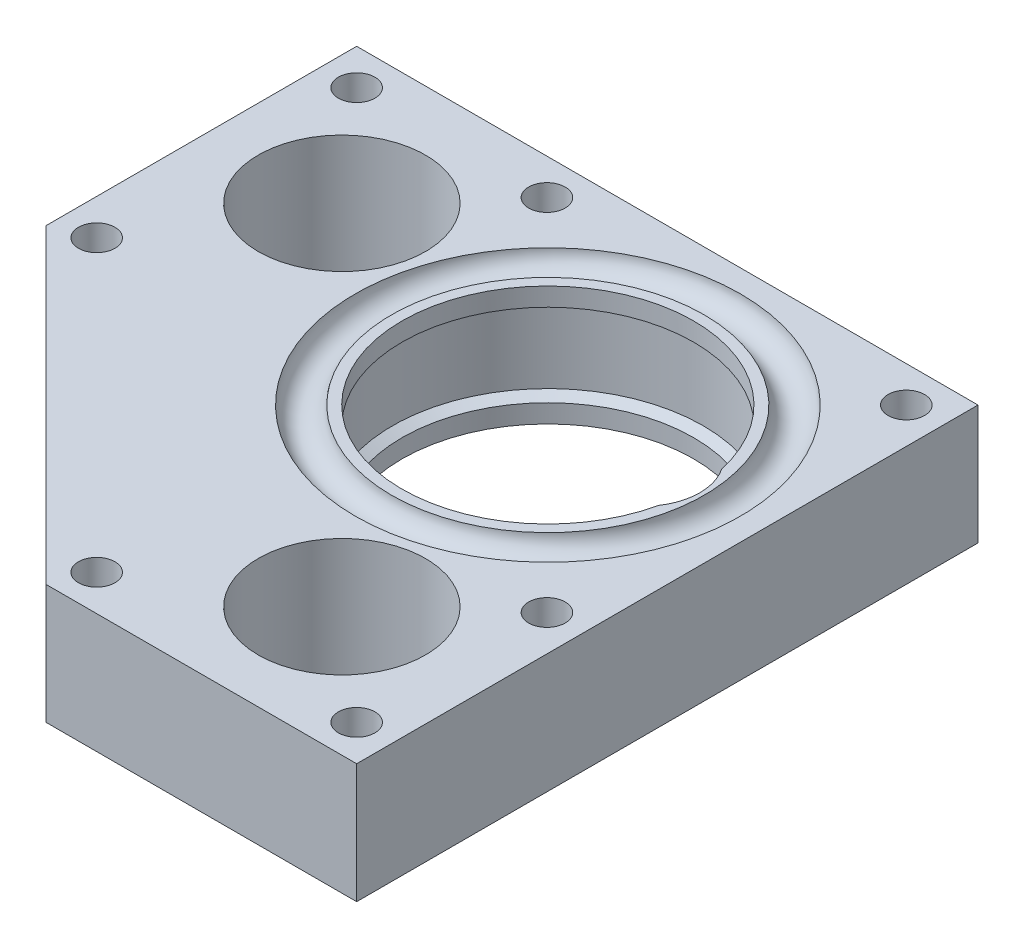
from build123d import *

# Parameters (mm, degrees)
SKETCH3_R               = 7.493
CUT_EXTRUDE2_DEPTH      = 8.9375
CUT_EXTRUDE2_DEPTH_BACK = 8.9375
SKETCH4_R               = 11.1125
SKETCH4_R_2             = 26.924
BOSS_EXTRUDE1_DEPTH     = 15.875
BOSS_EXTRUDE2_START     = 22.225
SKETCH7_R               = 6.35
BOSS_EXTRUDE2_DEPTH     = 4.7625
SKETCH5_R               = 2.4257
CUT_EXTRUDE3_DEPTH      = 27.9875
CUT_EXTRUDE3_DEPTH_BACK = 16.8750001


with BuildPart() as part:
    # Sketch1 → Revolve1 (revolve)
    with BuildSketch(Plane(origin=(0, 0, 0), x_dir=(0, 0, -1), z_dir=(1, 0, 0))):
        with BuildLine():
            Line((-20.6375, 0), (-26.9875, 0))
            Line((-26.9875, 0), (-26.9875, 7.9375))
            Line((-26.9875, 7.9375), (-25.587155577, 7.9375))
            ThreePointArc((-25.587155577, 7.9375), (-23.1775, 5.6515), (-20.767844423, 7.9375))
            Line((-20.767844423, 7.9375), (-19.3675, 7.9375))
            Line((-19.3675, 7.9375), (-19.3675, 5.495734842))
            Line((-19.3675, 5.495734842), (-20.6375, 4.7625))
            Line((-20.6375, 4.7625), (-20.6375, 0))
        make_face()
    revolve(axis=Axis((0, 0, 0), (0, 1, 0)))

    # Mirror1: part across plane


with BuildPart() as part_1:
    add(part.part)
    add(part.part.mirror(Plane(origin=(0, 0, 20.6375), x_dir=(0, 0, 1), z_dir=(0, 1, 0))))

    # Sketch3 → Cut-Extrude2 (cut, two sides)
    with BuildSketch(Plane(origin=(0, 0, 0), x_dir=(1, 0, 0), z_dir=(0, 1, 0))) as cut_extrude2_sk:
        with Locations((12.7, 0)):
            Circle(SKETCH3_R)
    extrude(amount=CUT_EXTRUDE2_DEPTH, mode=Mode.SUBTRACT)
    extrude(cut_extrude2_sk.sketch, amount=-CUT_EXTRUDE2_DEPTH_BACK, mode=Mode.SUBTRACT)

    # Sketch4 → Boss-Extrude1 (add, through all)
    with BuildSketch(Plane(origin=(0, 7.9375, 0), x_dir=(1, 0, 0), z_dir=(0, 1, 0))):
        Polygon((28.575, 28.575), (-53.975, 28.575), (-53.975, -12.7), (-12.7, -53.975), (28.575, -53.975), align=None)
        with Locations((-36.890166373, 9.525)):
            Circle(SKETCH4_R, mode=Mode.SUBTRACT)
        with Locations((9.525, -36.890166373)):
            Circle(SKETCH4_R, mode=Mode.SUBTRACT)
        Circle(SKETCH4_R_2, mode=Mode.SUBTRACT)
    extrude(amount=-BOSS_EXTRUDE1_DEPTH)


with BuildPart() as body_2:
    # Sketch7 → Boss-Extrude2 (new body)
    with BuildSketch(Plane(origin=(0, 7.9375, 0), x_dir=(1, 0, 0), z_dir=(0, 1, 0)).offset(BOSS_EXTRUDE2_START)):
        Polygon((28.575, -53.975), (28.575, 28.575), (-53.975, 28.575), (-53.975, -12.7), (-12.7, -53.975), align=None)
        Circle(SKETCH7_R, mode=Mode.SUBTRACT)
    extrude(amount=BOSS_EXTRUDE2_DEPTH)


with BuildPart() as cut_extrude3_tool:
    # Sketch5 → Cut-Extrude3 (new body, two sides)
    with BuildSketch(Plane(origin=(0, 7.9375, 0), x_dir=(1, 0, 0), z_dir=(0, 1, 0))) as cut_extrude3_sk:
        with Locations((23.8125, 23.8125)):
            Circle(SKETCH5_R)
        with Locations((-49.2125, 23.8125)):
            Circle(SKETCH5_R)
        with Locations((-23.933885369, 23.8125)):
            Circle(SKETCH5_R)
        with Locations((-49.2125, -10.727307909)):
            Circle(SKETCH5_R)
        with Locations((23.8125, -23.933885369)):
            Circle(SKETCH5_R)
        with Locations((23.8125, -49.2125)):
            Circle(SKETCH5_R)
        with Locations((-10.727307909, -49.2125)):
            Circle(SKETCH5_R)
    extrude(amount=CUT_EXTRUDE3_DEPTH)
    extrude(cut_extrude3_sk.sketch, amount=-CUT_EXTRUDE3_DEPTH_BACK)


with BuildPart() as part_2:
    add(part_1.part)

    # Cut-Extrude3: cut by cut_extrude3_tool
    add(cut_extrude3_tool.part, mode=Mode.SUBTRACT)


with BuildPart() as body_2_1:
    add(body_2.part)

    # Cut-Extrude3: cut by cut_extrude3_tool
    add(cut_extrude3_tool.part, mode=Mode.SUBTRACT)


solid = part_2.part
